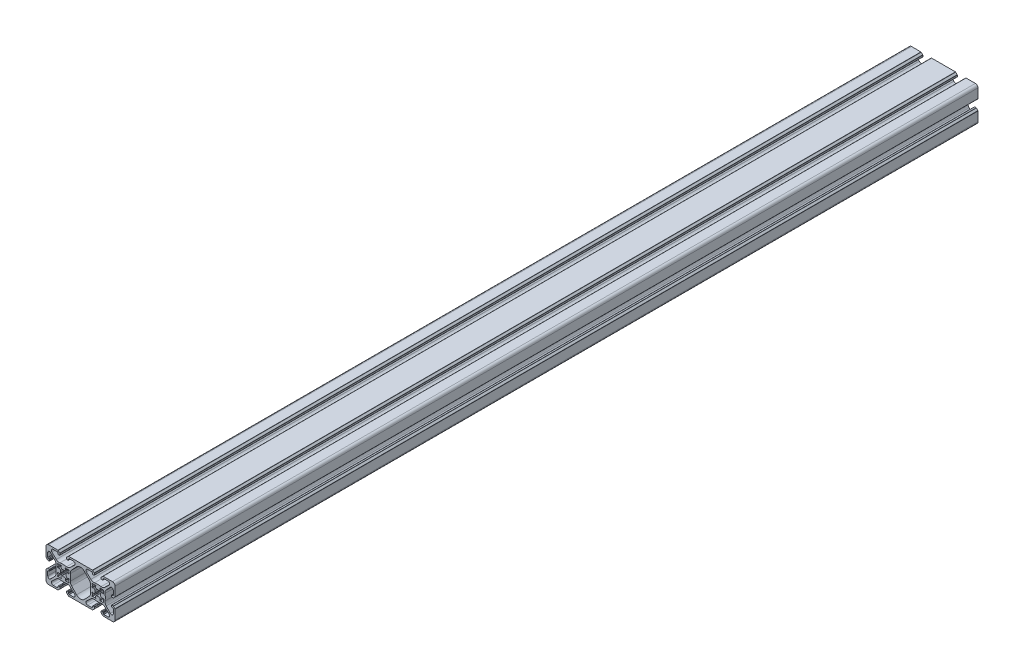
from build123d import *

# Parameters (mm, degrees)
BOSS_EXTRUDE1_DEPTH = 1000


with BuildPart() as part:
    # Model → Boss-Extrude1 (new body)
    with BuildSketch(Plane.XY):
        with BuildLine():
            Line((2004.58284826, 1674.680822833), (1976.997061823, 1674.680822833))
            ThreePointArc((1976.997061823, 1674.680822833), (1976.805720107, 1674.642762599), (1976.643508432, 1674.534376224))
            Line((1976.643508432, 1674.534376224), (1974.936401651, 1672.827269442))
            ThreePointArc((1974.936401651, 1672.827269442), (1974.828015275, 1672.665057768), (1974.789955042, 1672.473716052))
            Line((1974.789955042, 1672.473716052), (1974.789955042, 1670.880822833))
            ThreePointArc((1974.789955042, 1670.880822833), (1974.936401651, 1670.527269442), (1975.289955042, 1670.380822833))
            Line((1975.289955042, 1670.380822833), (1976.289955042, 1670.380822833))
            ThreePointArc((1976.289955042, 1670.380822833), (1976.643508432, 1670.527269442), (1976.789955042, 1670.880822833))
            Line((1976.789955042, 1670.880822833), (1976.789955042, 1671.72813164))
            ThreePointArc((1976.789955042, 1671.72813164), (1976.812791182, 1671.842936669), (1976.877823007, 1671.940263674))
            Line((1976.877823007, 1671.940263674), (1977.530514201, 1672.592954867))
            ThreePointArc((1977.530514201, 1672.592954867), (1977.627841205, 1672.657986693), (1977.742646235, 1672.680822833))
            Line((1977.742646235, 1672.680822833), (1982.547314354, 1672.680822833))
            ThreePointArc((1982.547314354, 1672.680822833), (1984.404841702, 1671.422167661), (1983.924382646, 1669.230414987))
            Line((1983.924382646, 1669.230414987), (1978.836171865, 1664.399488465))
            ThreePointArc((1978.836171865, 1664.399488465), (1976.884007102, 1663.252836714), (1974.626243453, 1663.084727205))
            ThreePointArc((1974.626243453, 1663.084727205), (1970.789955042, 1663.380822833), (1966.95366663, 1663.084727205))
            ThreePointArc((1966.95366663, 1663.084727205), (1964.695902982, 1663.252836714), (1962.743738218, 1664.399488465))
            Line((1962.743738218, 1664.399488465), (1957.655527437, 1669.230414987))
            ThreePointArc((1957.655527437, 1669.230414987), (1957.175068381, 1671.422167661), (1959.032595729, 1672.680822833))
            Line((1959.032595729, 1672.680822833), (1963.837263848, 1672.680822833))
            ThreePointArc((1963.837263848, 1672.680822833), (1963.952068878, 1672.657986693), (1964.049395882, 1672.592954867))
            Line((1964.049395882, 1672.592954867), (1964.702087076, 1671.940263674))
            ThreePointArc((1964.702087076, 1671.940263674), (1964.767118901, 1671.842936669), (1964.789955042, 1671.72813164))
            Line((1964.789955042, 1671.72813164), (1964.789955042, 1670.880822833))
            ThreePointArc((1964.789955042, 1670.880822833), (1964.936401651, 1670.527269442), (1965.289955042, 1670.380822833))
            Line((1965.289955042, 1670.380822833), (1966.289955042, 1670.380822833))
            ThreePointArc((1966.289955042, 1670.380822833), (1966.643508432, 1670.527269442), (1966.789955042, 1670.880822833))
            Line((1966.789955042, 1670.880822833), (1966.789955042, 1672.473716052))
            ThreePointArc((1966.789955042, 1672.473716052), (1966.751894808, 1672.665057768), (1966.643508432, 1672.827269442))
            Line((1966.643508432, 1672.827269442), (1964.936401651, 1674.534376224))
            ThreePointArc((1964.936401651, 1674.534376224), (1964.774189977, 1674.642762599), (1964.58284826, 1674.680822833))
            Line((1964.58284826, 1674.680822833), (1953.789955042, 1674.680822833))
            ThreePointArc((1953.789955042, 1674.680822833), (1951.668634698, 1673.802143177), (1950.789955042, 1671.680822833))
            Line((1950.789955042, 1671.680822833), (1950.789955042, 1660.887929614))
            ThreePointArc((1950.789955042, 1660.887929614), (1950.828015275, 1660.696587898), (1950.936401651, 1660.534376224))
            Line((1950.936401651, 1660.534376224), (1952.643508432, 1658.827269442))
            ThreePointArc((1952.643508432, 1658.827269442), (1952.805720107, 1658.718883067), (1952.997061823, 1658.680822833))
            Line((1952.997061823, 1658.680822833), (1954.589955042, 1658.680822833))
            ThreePointArc((1954.589955042, 1658.680822833), (1954.943508432, 1658.827269442), (1955.089955042, 1659.180822833))
            Line((1955.089955042, 1659.180822833), (1955.089955042, 1660.180822833))
            ThreePointArc((1955.089955042, 1660.180822833), (1954.943508432, 1660.534376224), (1954.589955042, 1660.680822833))
            Line((1954.589955042, 1660.680822833), (1953.742646235, 1660.680822833))
            ThreePointArc((1953.742646235, 1660.680822833), (1953.627841205, 1660.703658973), (1953.530514201, 1660.768690799))
            Line((1953.530514201, 1660.768690799), (1952.877823007, 1661.421381992))
            ThreePointArc((1952.877823007, 1661.421381992), (1952.812791182, 1661.518708997), (1952.789955042, 1661.633514026))
            Line((1952.789955042, 1661.633514026), (1952.789955042, 1666.438182146))
            ThreePointArc((1952.789955042, 1666.438182146), (1954.048610213, 1668.295709493), (1956.240362887, 1667.815250438))
            Line((1956.240362887, 1667.815250438), (1961.07128941, 1662.727039656))
            ThreePointArc((1961.07128941, 1662.727039656), (1962.217941161, 1660.774874893), (1962.386050669, 1658.517111244))
            ThreePointArc((1962.386050669, 1658.517111244), (1962.089955042, 1654.680822833), (1962.386050669, 1650.844534422))
            ThreePointArc((1962.386050669, 1650.844534422), (1962.217941161, 1648.586770773), (1961.07128941, 1646.63460601))
            Line((1961.07128941, 1646.63460601), (1956.240362887, 1641.546395228))
            ThreePointArc((1956.240362887, 1641.546395228), (1954.048610213, 1641.065936173), (1952.789955042, 1642.92346352))
            Line((1952.789955042, 1642.92346352), (1952.789955042, 1647.72813164))
            ThreePointArc((1952.789955042, 1647.72813164), (1952.812791182, 1647.842936669), (1952.877823007, 1647.940263674))
            Line((1952.877823007, 1647.940263674), (1953.530514201, 1648.592954867))
            ThreePointArc((1953.530514201, 1648.592954867), (1953.627841205, 1648.657986693), (1953.742646235, 1648.680822833))
            Line((1953.742646235, 1648.680822833), (1954.589955042, 1648.680822833))
            ThreePointArc((1954.589955042, 1648.680822833), (1954.943508432, 1648.827269442), (1955.089955042, 1649.180822833))
            Line((1955.089955042, 1649.180822833), (1955.089955042, 1650.180822833))
            ThreePointArc((1955.089955042, 1650.180822833), (1954.943508432, 1650.534376224), (1954.589955042, 1650.680822833))
            Line((1954.589955042, 1650.680822833), (1952.997061823, 1650.680822833))
            ThreePointArc((1952.997061823, 1650.680822833), (1952.805720107, 1650.642762599), (1952.643508432, 1650.534376224))
            Line((1952.643508432, 1650.534376224), (1950.936401651, 1648.827269442))
            ThreePointArc((1950.936401651, 1648.827269442), (1950.828015275, 1648.665057768), (1950.789955042, 1648.473716052))
            Line((1950.789955042, 1648.473716052), (1950.789955042, 1637.680822833))
            ThreePointArc((1950.789955042, 1637.680822833), (1951.668634698, 1635.559502489), (1953.789955042, 1634.680822833))
            Line((1953.789955042, 1634.680822833), (1964.58284826, 1634.680822833))
            ThreePointArc((1964.58284826, 1634.680822833), (1964.774189977, 1634.718883067), (1964.936401651, 1634.827269442))
            Line((1964.936401651, 1634.827269442), (1966.643508432, 1636.534376224))
            ThreePointArc((1966.643508432, 1636.534376224), (1966.751894808, 1636.696587898), (1966.789955042, 1636.887929614))
            Line((1966.789955042, 1636.887929614), (1966.789955042, 1638.480822833))
            ThreePointArc((1966.789955042, 1638.480822833), (1966.643508432, 1638.834376224), (1966.289955042, 1638.980822833))
            Line((1966.289955042, 1638.980822833), (1965.289955042, 1638.980822833))
            ThreePointArc((1965.289955042, 1638.980822833), (1964.936401651, 1638.834376224), (1964.789955042, 1638.480822833))
            Line((1964.789955042, 1638.480822833), (1964.789955042, 1637.633514026))
            ThreePointArc((1964.789955042, 1637.633514026), (1964.767118901, 1637.518708997), (1964.702087076, 1637.421381992))
            Line((1964.702087076, 1637.421381992), (1964.049395882, 1636.768690799))
            ThreePointArc((1964.049395882, 1636.768690799), (1963.952068878, 1636.703658973), (1963.837263848, 1636.680822833))
            Line((1963.837263848, 1636.680822833), (1959.032595729, 1636.680822833))
            ThreePointArc((1959.032595729, 1636.680822833), (1957.175068381, 1637.939478005), (1957.655527437, 1640.131230679))
            Line((1957.655527437, 1640.131230679), (1962.743738218, 1644.962157201))
            ThreePointArc((1962.743738218, 1644.962157201), (1964.695902982, 1646.108808952), (1966.95366663, 1646.276918461))
            ThreePointArc((1966.95366663, 1646.276918461), (1970.789955042, 1645.980822833), (1974.626243453, 1646.276918461))
            ThreePointArc((1974.626243453, 1646.276918461), (1976.884007102, 1646.108808952), (1978.836171865, 1644.962157201))
            Line((1978.836171865, 1644.962157201), (1983.924382646, 1640.131230679))
            ThreePointArc((1983.924382646, 1640.131230679), (1984.404841702, 1637.939478005), (1982.547314354, 1636.680822833))
            Line((1982.547314354, 1636.680822833), (1977.742646235, 1636.680822833))
            ThreePointArc((1977.742646235, 1636.680822833), (1977.627841205, 1636.703658973), (1977.530514201, 1636.768690799))
            Line((1977.530514201, 1636.768690799), (1976.877823007, 1637.421381992))
            ThreePointArc((1976.877823007, 1637.421381992), (1976.812791182, 1637.518708997), (1976.789955042, 1637.633514026))
            Line((1976.789955042, 1637.633514026), (1976.789955042, 1638.480822833))
            ThreePointArc((1976.789955042, 1638.480822833), (1976.643508432, 1638.834376224), (1976.289955042, 1638.980822833))
            Line((1976.289955042, 1638.980822833), (1975.289955042, 1638.980822833))
            ThreePointArc((1975.289955042, 1638.980822833), (1974.936401651, 1638.834376224), (1974.789955042, 1638.480822833))
            Line((1974.789955042, 1638.480822833), (1974.789955042, 1636.887929614))
            ThreePointArc((1974.789955042, 1636.887929614), (1974.828015275, 1636.696587898), (1974.936401651, 1636.534376224))
            Line((1974.936401651, 1636.534376224), (1976.643508432, 1634.827269442))
            ThreePointArc((1976.643508432, 1634.827269442), (1976.805720107, 1634.718883067), (1976.997061823, 1634.680822833))
            Line((1976.997061823, 1634.680822833), (2004.58284826, 1634.680822833))
            ThreePointArc((2004.58284826, 1634.680822833), (2004.774189977, 1634.718883067), (2004.936401651, 1634.827269442))
            Line((2004.936401651, 1634.827269442), (2006.643508432, 1636.534376224))
            ThreePointArc((2006.643508432, 1636.534376224), (2006.751894808, 1636.696587898), (2006.789955042, 1636.887929614))
            Line((2006.789955042, 1636.887929614), (2006.789955042, 1638.480822833))
            ThreePointArc((2006.789955042, 1638.480822833), (2006.643508432, 1638.834376224), (2006.289955042, 1638.980822833))
            Line((2006.289955042, 1638.980822833), (2005.289955042, 1638.980822833))
            ThreePointArc((2005.289955042, 1638.980822833), (2004.936401651, 1638.834376224), (2004.789955042, 1638.480822833))
            Line((2004.789955042, 1638.480822833), (2004.789955042, 1637.633514026))
            ThreePointArc((2004.789955042, 1637.633514026), (2004.767118901, 1637.518708997), (2004.702087076, 1637.421381992))
            Line((2004.702087076, 1637.421381992), (2004.049395882, 1636.768690799))
            ThreePointArc((2004.049395882, 1636.768690799), (2003.952068878, 1636.703658973), (2003.837263848, 1636.680822833))
            Line((2003.837263848, 1636.680822833), (1999.032595729, 1636.680822833))
            ThreePointArc((1999.032595729, 1636.680822833), (1997.175068381, 1637.939478005), (1997.655527437, 1640.131230679))
            Line((1997.655527437, 1640.131230679), (2002.743738218, 1644.962157201))
            ThreePointArc((2002.743738218, 1644.962157201), (2004.695902982, 1646.108808952), (2006.95366663, 1646.276918461))
            ThreePointArc((2006.95366663, 1646.276918461), (2010.789955042, 1645.980822833), (2014.626243453, 1646.276918461))
            ThreePointArc((2014.626243453, 1646.276918461), (2016.884007102, 1646.108808952), (2018.836171865, 1644.962157201))
            Line((2018.836171865, 1644.962157201), (2023.924382646, 1640.131230679))
            ThreePointArc((2023.924382646, 1640.131230679), (2024.404841702, 1637.939478005), (2022.547314354, 1636.680822833))
            Line((2022.547314354, 1636.680822833), (2017.742646235, 1636.680822833))
            ThreePointArc((2017.742646235, 1636.680822833), (2017.627841205, 1636.703658973), (2017.530514201, 1636.768690799))
            Line((2017.530514201, 1636.768690799), (2016.877823007, 1637.421381992))
            ThreePointArc((2016.877823007, 1637.421381992), (2016.812791182, 1637.518708997), (2016.789955042, 1637.633514026))
            Line((2016.789955042, 1637.633514026), (2016.789955042, 1638.480822833))
            ThreePointArc((2016.789955042, 1638.480822833), (2016.643508432, 1638.834376224), (2016.289955042, 1638.980822833))
            Line((2016.289955042, 1638.980822833), (2015.289955042, 1638.980822833))
            ThreePointArc((2015.289955042, 1638.980822833), (2014.936401651, 1638.834376224), (2014.789955042, 1638.480822833))
            Line((2014.789955042, 1638.480822833), (2014.789955042, 1636.887929614))
            ThreePointArc((2014.789955042, 1636.887929614), (2014.828015275, 1636.696587898), (2014.936401651, 1636.534376224))
            Line((2014.936401651, 1636.534376224), (2016.643508432, 1634.827269442))
            ThreePointArc((2016.643508432, 1634.827269442), (2016.805720107, 1634.718883067), (2016.997061823, 1634.680822833))
            Line((2016.997061823, 1634.680822833), (2027.789955042, 1634.680822833))
            ThreePointArc((2027.789955042, 1634.680822833), (2029.911275385, 1635.559502489), (2030.789955042, 1637.680822833))
            Line((2030.789955042, 1637.680822833), (2030.789955042, 1648.473716052))
            ThreePointArc((2030.789955042, 1648.473716052), (2030.751894808, 1648.665057768), (2030.643508432, 1648.827269442))
            Line((2030.643508432, 1648.827269442), (2028.936401651, 1650.534376224))
            ThreePointArc((2028.936401651, 1650.534376224), (2028.774189977, 1650.642762599), (2028.58284826, 1650.680822833))
            Line((2028.58284826, 1650.680822833), (2026.989955042, 1650.680822833))
            ThreePointArc((2026.989955042, 1650.680822833), (2026.636401651, 1650.534376224), (2026.489955042, 1650.180822833))
            Line((2026.489955042, 1650.180822833), (2026.489955042, 1649.180822833))
            ThreePointArc((2026.489955042, 1649.180822833), (2026.636401651, 1648.827269442), (2026.989955042, 1648.680822833))
            Line((2026.989955042, 1648.680822833), (2027.837263848, 1648.680822833))
            ThreePointArc((2027.837263848, 1648.680822833), (2027.952068878, 1648.657986693), (2028.049395882, 1648.592954867))
            Line((2028.049395882, 1648.592954867), (2028.702087076, 1647.940263674))
            ThreePointArc((2028.702087076, 1647.940263674), (2028.767118901, 1647.842936669), (2028.789955042, 1647.72813164))
            Line((2028.789955042, 1647.72813164), (2028.789955042, 1642.92346352))
            ThreePointArc((2028.789955042, 1642.92346352), (2027.53129987, 1641.065936173), (2025.339547196, 1641.546395228))
            Line((2025.339547196, 1641.546395228), (2020.508620674, 1646.63460601))
            ThreePointArc((2020.508620674, 1646.63460601), (2019.361968923, 1648.586770773), (2019.193859414, 1650.844534422))
            ThreePointArc((2019.193859414, 1650.844534422), (2019.489955042, 1654.680822833), (2019.193859414, 1658.517111244))
            ThreePointArc((2019.193859414, 1658.517111244), (2019.361968923, 1660.774874893), (2020.508620674, 1662.727039656))
            Line((2020.508620674, 1662.727039656), (2025.339547196, 1667.815250438))
            ThreePointArc((2025.339547196, 1667.815250438), (2027.53129987, 1668.295709493), (2028.789955042, 1666.438182146))
            Line((2028.789955042, 1666.438182146), (2028.789955042, 1661.633514026))
            ThreePointArc((2028.789955042, 1661.633514026), (2028.767118901, 1661.518708997), (2028.702087076, 1661.421381992))
            Line((2028.702087076, 1661.421381992), (2028.049395882, 1660.768690799))
            ThreePointArc((2028.049395882, 1660.768690799), (2027.952068878, 1660.703658973), (2027.837263848, 1660.680822833))
            Line((2027.837263848, 1660.680822833), (2026.989955042, 1660.680822833))
            ThreePointArc((2026.989955042, 1660.680822833), (2026.636401651, 1660.534376224), (2026.489955042, 1660.180822833))
            Line((2026.489955042, 1660.180822833), (2026.489955042, 1659.180822833))
            ThreePointArc((2026.489955042, 1659.180822833), (2026.636401651, 1658.827269442), (2026.989955042, 1658.680822833))
            Line((2026.989955042, 1658.680822833), (2028.58284826, 1658.680822833))
            ThreePointArc((2028.58284826, 1658.680822833), (2028.774189977, 1658.718883067), (2028.936401651, 1658.827269442))
            Line((2028.936401651, 1658.827269442), (2030.643508432, 1660.534376224))
            ThreePointArc((2030.643508432, 1660.534376224), (2030.751894808, 1660.696587898), (2030.789955042, 1660.887929614))
            Line((2030.789955042, 1660.887929614), (2030.789955042, 1671.680822833))
            ThreePointArc((2030.789955042, 1671.680822833), (2029.911275385, 1673.802143177), (2027.789955042, 1674.680822833))
            Line((2027.789955042, 1674.680822833), (2016.997061823, 1674.680822833))
            ThreePointArc((2016.997061823, 1674.680822833), (2016.805720107, 1674.642762599), (2016.643508432, 1674.534376224))
            Line((2016.643508432, 1674.534376224), (2014.936401651, 1672.827269442))
            ThreePointArc((2014.936401651, 1672.827269442), (2014.828015275, 1672.665057768), (2014.789955042, 1672.473716052))
            Line((2014.789955042, 1672.473716052), (2014.789955042, 1670.880822833))
            ThreePointArc((2014.789955042, 1670.880822833), (2014.936401651, 1670.527269442), (2015.289955042, 1670.380822833))
            Line((2015.289955042, 1670.380822833), (2016.289955042, 1670.380822833))
            ThreePointArc((2016.289955042, 1670.380822833), (2016.643508432, 1670.527269442), (2016.789955042, 1670.880822833))
            Line((2016.789955042, 1670.880822833), (2016.789955042, 1671.72813164))
            ThreePointArc((2016.789955042, 1671.72813164), (2016.812791182, 1671.842936669), (2016.877823007, 1671.940263674))
            Line((2016.877823007, 1671.940263674), (2017.530514201, 1672.592954867))
            ThreePointArc((2017.530514201, 1672.592954867), (2017.627841205, 1672.657986693), (2017.742646235, 1672.680822833))
            Line((2017.742646235, 1672.680822833), (2022.547314354, 1672.680822833))
            ThreePointArc((2022.547314354, 1672.680822833), (2024.404841702, 1671.422167661), (2023.924382646, 1669.230414987))
            Line((2023.924382646, 1669.230414987), (2018.836171865, 1664.399488465))
            ThreePointArc((2018.836171865, 1664.399488465), (2016.884007102, 1663.252836714), (2014.626243453, 1663.084727205))
            ThreePointArc((2014.626243453, 1663.084727205), (2010.789955042, 1663.380822833), (2006.95366663, 1663.084727205))
            ThreePointArc((2006.95366663, 1663.084727205), (2004.695902982, 1663.252836714), (2002.743738218, 1664.399488465))
            Line((2002.743738218, 1664.399488465), (1997.655527437, 1669.230414987))
            ThreePointArc((1997.655527437, 1669.230414987), (1997.175068381, 1671.422167661), (1999.032595729, 1672.680822833))
            Line((1999.032595729, 1672.680822833), (2003.837263848, 1672.680822833))
            ThreePointArc((2003.837263848, 1672.680822833), (2003.952068878, 1672.657986693), (2004.049395882, 1672.592954867))
            Line((2004.049395882, 1672.592954867), (2004.702087076, 1671.940263674))
            ThreePointArc((2004.702087076, 1671.940263674), (2004.767118901, 1671.842936669), (2004.789955042, 1671.72813164))
            Line((2004.789955042, 1671.72813164), (2004.789955042, 1670.880822833))
            ThreePointArc((2004.789955042, 1670.880822833), (2004.936401651, 1670.527269442), (2005.289955042, 1670.380822833))
            Line((2005.289955042, 1670.380822833), (2006.289955042, 1670.380822833))
            ThreePointArc((2006.289955042, 1670.380822833), (2006.643508432, 1670.527269442), (2006.789955042, 1670.880822833))
            Line((2006.789955042, 1670.880822833), (2006.789955042, 1672.473716052))
            ThreePointArc((2006.789955042, 1672.473716052), (2006.751894808, 1672.665057768), (2006.643508432, 1672.827269442))
            Line((2006.643508432, 1672.827269442), (2004.936401651, 1674.534376224))
            ThreePointArc((2004.936401651, 1674.534376224), (2004.774189977, 1674.642762599), (2004.58284826, 1674.680822833))
        make_face()
        with BuildLine():
            Line((1975.954093645, 1652.136177126), (1976.967157252, 1652.407626702))
            ThreePointArc((1976.967157252, 1652.407626702), (1977.240596937, 1652.345147703), (1977.342884657, 1652.083977053))
            ThreePointArc((1977.342884657, 1652.083977053), (1977.283896837, 1651.608980156), (1977.215037318, 1651.135313626))
            ThreePointArc((1977.215037318, 1651.135313626), (1977.135083445, 1649.82816552), (1977.300003597, 1648.52900035))
            ThreePointArc((1977.300003597, 1648.52900035), (1977.219362927, 1648.251414947), (1976.941777525, 1648.170774277))
            ThreePointArc((1976.941777525, 1648.170774277), (1975.642612355, 1648.33569443), (1974.335464248, 1648.255740557))
            ThreePointArc((1974.335464248, 1648.255740557), (1973.861797719, 1648.186881038), (1973.386800822, 1648.127893218))
            ThreePointArc((1973.386800822, 1648.127893218), (1973.125630172, 1648.230180938), (1973.063151173, 1648.503620622))
            Line((1973.063151173, 1648.503620622), (1973.334600748, 1649.51668423))
            ThreePointArc((1973.334600748, 1649.51668423), (1972.96543099, 1650.94616537), (1971.550276202, 1651.366926074))
            ThreePointArc((1971.550276202, 1651.366926074), (1970.789955042, 1651.280822833), (1970.029633881, 1651.366926074))
            ThreePointArc((1970.029633881, 1651.366926074), (1968.614479093, 1650.94616537), (1968.245309335, 1649.51668423))
            Line((1968.245309335, 1649.51668423), (1968.516758911, 1648.503620622))
            ThreePointArc((1968.516758911, 1648.503620622), (1968.454279911, 1648.230180938), (1968.193109261, 1648.127893218))
            ThreePointArc((1968.193109261, 1648.127893218), (1967.718112364, 1648.186881038), (1967.244445835, 1648.255740557))
            ThreePointArc((1967.244445835, 1648.255740557), (1965.937297728, 1648.33569443), (1964.638132559, 1648.170774277))
            ThreePointArc((1964.638132559, 1648.170774277), (1964.360547156, 1648.251414947), (1964.279906486, 1648.52900035))
            ThreePointArc((1964.279906486, 1648.52900035), (1964.444826638, 1649.82816552), (1964.364872765, 1651.135313626))
            ThreePointArc((1964.364872765, 1651.135313626), (1964.296013246, 1651.608980156), (1964.237025426, 1652.083977053))
            ThreePointArc((1964.237025426, 1652.083977053), (1964.339313147, 1652.345147703), (1964.612752831, 1652.407626702))
            Line((1964.612752831, 1652.407626702), (1965.625816438, 1652.136177126))
            ThreePointArc((1965.625816438, 1652.136177126), (1967.055297579, 1652.505346884), (1967.476058282, 1653.920501672))
            ThreePointArc((1967.476058282, 1653.920501672), (1967.389955042, 1654.680822833), (1967.476058282, 1655.441143994))
            ThreePointArc((1967.476058282, 1655.441143994), (1967.055297579, 1656.856298782), (1965.625816438, 1657.22546854))
            Line((1965.625816438, 1657.22546854), (1964.612752831, 1656.954018964))
            ThreePointArc((1964.612752831, 1656.954018964), (1964.339313147, 1657.016497963), (1964.237025426, 1657.277668613))
            ThreePointArc((1964.237025426, 1657.277668613), (1964.296013246, 1657.75266551), (1964.364872765, 1658.22633204))
            ThreePointArc((1964.364872765, 1658.22633204), (1964.444826638, 1659.533480146), (1964.279906486, 1660.832645316))
            ThreePointArc((1964.279906486, 1660.832645316), (1964.360547156, 1661.110230718), (1964.638132559, 1661.190871389))
            ThreePointArc((1964.638132559, 1661.190871389), (1965.937297728, 1661.025951236), (1967.244445835, 1661.105905109))
            ThreePointArc((1967.244445835, 1661.105905109), (1967.718112364, 1661.174764628), (1968.193109261, 1661.233752448))
            ThreePointArc((1968.193109261, 1661.233752448), (1968.454279911, 1661.131464728), (1968.516758911, 1660.858025044))
            Line((1968.516758911, 1660.858025044), (1968.245309335, 1659.844961436))
            ThreePointArc((1968.245309335, 1659.844961436), (1968.614479093, 1658.415480295), (1970.029633881, 1657.994719592))
            ThreePointArc((1970.029633881, 1657.994719592), (1970.789955042, 1658.080822833), (1971.550276202, 1657.994719592))
            ThreePointArc((1971.550276202, 1657.994719592), (1972.96543099, 1658.415480295), (1973.334600748, 1659.844961436))
            Line((1973.334600748, 1659.844961436), (1973.063151173, 1660.858025044))
            ThreePointArc((1973.063151173, 1660.858025044), (1973.125630172, 1661.131464728), (1973.386800822, 1661.233752448))
            ThreePointArc((1973.386800822, 1661.233752448), (1973.861797719, 1661.174764628), (1974.335464248, 1661.105905109))
            ThreePointArc((1974.335464248, 1661.105905109), (1975.642612355, 1661.025951236), (1976.941777525, 1661.190871389))
            ThreePointArc((1976.941777525, 1661.190871389), (1977.219362927, 1661.110230718), (1977.300003597, 1660.832645316))
            ThreePointArc((1977.300003597, 1660.832645316), (1977.135083445, 1659.533480146), (1977.215037318, 1658.22633204))
            ThreePointArc((1977.215037318, 1658.22633204), (1977.283896837, 1657.75266551), (1977.342884657, 1657.277668613))
            ThreePointArc((1977.342884657, 1657.277668613), (1977.240596937, 1657.016497963), (1976.967157252, 1656.954018964))
            Line((1976.967157252, 1656.954018964), (1975.954093645, 1657.22546854))
            ThreePointArc((1975.954093645, 1657.22546854), (1974.524612504, 1656.856298782), (1974.103851801, 1655.441143994))
            ThreePointArc((1974.103851801, 1655.441143994), (1974.189955042, 1654.680822833), (1974.103851801, 1653.920501672))
            ThreePointArc((1974.103851801, 1653.920501672), (1974.524612504, 1652.505346884), (1975.954093645, 1652.136177126))
        make_face(mode=Mode.SUBTRACT)
        with BuildLine():
            Line((2005.625816438, 1652.136177126), (2004.612752831, 1652.407626702))
            ThreePointArc((2004.612752831, 1652.407626702), (2004.339313147, 1652.345147703), (2004.237025426, 1652.083977053))
            ThreePointArc((2004.237025426, 1652.083977053), (2004.296013246, 1651.608980156), (2004.364872765, 1651.135313626))
            ThreePointArc((2004.364872765, 1651.135313626), (2004.444826638, 1649.82816552), (2004.279906486, 1648.52900035))
            ThreePointArc((2004.279906486, 1648.52900035), (2004.360547156, 1648.251414947), (2004.638132559, 1648.170774277))
            ThreePointArc((2004.638132559, 1648.170774277), (2005.937297728, 1648.33569443), (2007.244445835, 1648.255740557))
            ThreePointArc((2007.244445835, 1648.255740557), (2007.718112364, 1648.186881038), (2008.193109261, 1648.127893218))
            ThreePointArc((2008.193109261, 1648.127893218), (2008.454279911, 1648.230180938), (2008.516758911, 1648.503620622))
            Line((2008.516758911, 1648.503620622), (2008.245309335, 1649.51668423))
            ThreePointArc((2008.245309335, 1649.51668423), (2008.614479093, 1650.946165371), (2010.029633881, 1651.366926074))
            ThreePointArc((2010.029633881, 1651.366926074), (2010.789955042, 1651.280822833), (2011.550276202, 1651.366926074))
            ThreePointArc((2011.550276202, 1651.366926074), (2012.96543099, 1650.946165371), (2013.334600748, 1649.51668423))
            Line((2013.334600748, 1649.51668423), (2013.063151173, 1648.503620622))
            ThreePointArc((2013.063151173, 1648.503620622), (2013.125630172, 1648.230180938), (2013.386800822, 1648.127893218))
            ThreePointArc((2013.386800822, 1648.127893218), (2013.861797719, 1648.186881038), (2014.335464248, 1648.255740557))
            ThreePointArc((2014.335464248, 1648.255740557), (2015.642612355, 1648.33569443), (2016.941777525, 1648.170774277))
            ThreePointArc((2016.941777525, 1648.170774277), (2017.219362927, 1648.251414947), (2017.300003597, 1648.52900035))
            ThreePointArc((2017.300003597, 1648.52900035), (2017.135083445, 1649.82816552), (2017.215037318, 1651.135313626))
            ThreePointArc((2017.215037318, 1651.135313626), (2017.283896837, 1651.608980156), (2017.342884657, 1652.083977053))
            ThreePointArc((2017.342884657, 1652.083977053), (2017.240596937, 1652.345147703), (2016.967157252, 1652.407626702))
            Line((2016.967157252, 1652.407626702), (2015.954093645, 1652.136177126))
            ThreePointArc((2015.954093645, 1652.136177126), (2014.524612504, 1652.505346884), (2014.103851801, 1653.920501672))
            ThreePointArc((2014.103851801, 1653.920501672), (2014.189955042, 1654.680822833), (2014.103851801, 1655.441143994))
            ThreePointArc((2014.103851801, 1655.441143994), (2014.524612504, 1656.856298782), (2015.954093645, 1657.22546854))
            Line((2015.954093645, 1657.22546854), (2016.967157252, 1656.954018964))
            ThreePointArc((2016.967157252, 1656.954018964), (2017.240596937, 1657.016497963), (2017.342884657, 1657.277668613))
            ThreePointArc((2017.342884657, 1657.277668613), (2017.283896837, 1657.75266551), (2017.215037318, 1658.22633204))
            ThreePointArc((2017.215037318, 1658.22633204), (2017.135083445, 1659.533480146), (2017.300003597, 1660.832645316))
            ThreePointArc((2017.300003597, 1660.832645316), (2017.219362927, 1661.110230718), (2016.941777525, 1661.190871389))
            ThreePointArc((2016.941777525, 1661.190871389), (2015.642612355, 1661.025951236), (2014.335464248, 1661.105905109))
            ThreePointArc((2014.335464248, 1661.105905109), (2013.861797719, 1661.174764628), (2013.386800822, 1661.233752448))
            ThreePointArc((2013.386800822, 1661.233752448), (2013.125630172, 1661.131464728), (2013.063151173, 1660.858025044))
            Line((2013.063151173, 1660.858025044), (2013.334600748, 1659.844961436))
            ThreePointArc((2013.334600748, 1659.844961436), (2012.96543099, 1658.415480295), (2011.550276202, 1657.994719592))
            ThreePointArc((2011.550276202, 1657.994719592), (2010.789955042, 1658.080822833), (2010.029633881, 1657.994719592))
            ThreePointArc((2010.029633881, 1657.994719592), (2008.614479093, 1658.415480295), (2008.245309335, 1659.844961436))
            Line((2008.245309335, 1659.844961436), (2008.516758911, 1660.858025044))
            ThreePointArc((2008.516758911, 1660.858025044), (2008.454279911, 1661.131464728), (2008.193109261, 1661.233752448))
            ThreePointArc((2008.193109261, 1661.233752448), (2007.718112364, 1661.174764628), (2007.244445835, 1661.105905109))
            ThreePointArc((2007.244445835, 1661.105905109), (2005.937297728, 1661.025951236), (2004.638132559, 1661.190871389))
            ThreePointArc((2004.638132559, 1661.190871389), (2004.360547156, 1661.110230718), (2004.279906486, 1660.832645316))
            ThreePointArc((2004.279906486, 1660.832645316), (2004.444826638, 1659.533480146), (2004.364872765, 1658.22633204))
            ThreePointArc((2004.364872765, 1658.22633204), (2004.296013246, 1657.75266551), (2004.237025426, 1657.277668613))
            ThreePointArc((2004.237025426, 1657.277668613), (2004.339313147, 1657.016497963), (2004.612752831, 1656.954018964))
            Line((2004.612752831, 1656.954018964), (2005.625816438, 1657.22546854))
            ThreePointArc((2005.625816438, 1657.22546854), (2007.055297579, 1656.856298782), (2007.476058282, 1655.441143994))
            ThreePointArc((2007.476058282, 1655.441143994), (2007.389955042, 1654.680822833), (2007.476058282, 1653.920501672))
            ThreePointArc((2007.476058282, 1653.920501672), (2007.055297579, 1652.505346884), (2005.625816438, 1652.136177126))
        make_face(mode=Mode.SUBTRACT)
        with BuildLine():
            Line((1980.508620674, 1646.63460601), (1986.180708525, 1640.660435542))
            ThreePointArc((1986.180708525, 1640.660435542), (1990.789955042, 1638.680822833), (1995.399201558, 1640.660435542))
            Line((1995.399201558, 1640.660435542), (2001.07128941, 1646.63460601))
            ThreePointArc((2001.07128941, 1646.63460601), (2002.217941161, 1648.586770773), (2002.386050669, 1650.844534422))
            ThreePointArc((2002.386050669, 1650.844534422), (2002.089955042, 1654.680822833), (2002.386050669, 1658.517111244))
            ThreePointArc((2002.386050669, 1658.517111244), (2002.217941161, 1660.774874893), (2001.07128941, 1662.727039656))
            Line((2001.07128941, 1662.727039656), (1995.399201558, 1668.701210124))
            ThreePointArc((1995.399201558, 1668.701210124), (1990.789955042, 1670.680822833), (1986.180708525, 1668.701210124))
            Line((1986.180708525, 1668.701210124), (1980.508620674, 1662.727039656))
            ThreePointArc((1980.508620674, 1662.727039656), (1979.361968923, 1660.774874893), (1979.193859414, 1658.517111244))
            ThreePointArc((1979.193859414, 1658.517111244), (1979.489955042, 1654.680822833), (1979.193859414, 1650.844534422))
            ThreePointArc((1979.193859414, 1650.844534422), (1979.361968923, 1648.586770773), (1980.508620674, 1646.63460601))
        make_face(mode=Mode.SUBTRACT)
    extrude(amount=BOSS_EXTRUDE1_DEPTH)


solid = part.part
